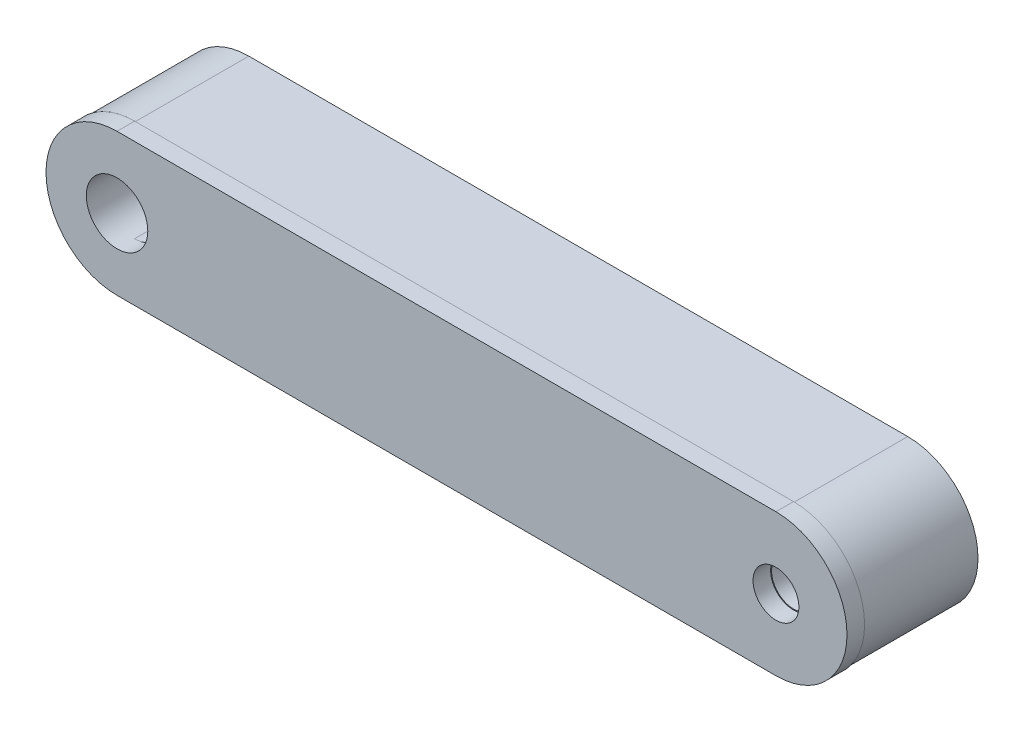
from build123d import *

# Parameters (mm, degrees)
SKETCH1_R           = 2.5
BOSS_EXTRUDE1_DEPTH = 13
SKETCH2_R           = 2.609917525
SKETCH2_R_2         = 3.5
BOSS_EXTRUDE2_DEPTH = 2


with BuildPart() as part:
    # Sketch1 → Boss-Extrude1 (new body)
    with BuildSketch(Plane.XY):
        with BuildLine():
            Line((-89.768287337, 45.333507938), (-14.768287337, 45.333507938))
            ThreePointArc((-14.768287337, 45.333507938), (-6.770739373, 37.335959975), (-14.768287337, 29.338412011))
            Line((-14.768287337, 29.338412011), (-89.768287337, 29.338412011))
            ThreePointArc((-89.768287337, 29.338412011), (-97.765835301, 37.335959975), (-89.768287337, 45.333507938))
        make_face()
        with Locations((-14.768287337, 37.335959975)):
            Circle(SKETCH1_R, mode=Mode.SUBTRACT)
        with BuildLine():
            Line((-89.768287337, 40.835959975), (-77.768287337, 40.835959975))
            ThreePointArc((-77.768287337, 40.835959975), (-74.268287337, 37.335959975), (-77.768287337, 33.835959975))
            Line((-77.768287337, 33.835959975), (-89.768287337, 33.835959975))
            ThreePointArc((-89.768287337, 33.835959975), (-93.268287337, 37.335959975), (-89.768287337, 40.835959975))
        make_face(mode=Mode.SUBTRACT)
    extrude(amount=BOSS_EXTRUDE1_DEPTH)

    # Sketch2 → Boss-Extrude2 (add)
    with BuildSketch(Plane.XY.offset(13)):
        with BuildLine():
            Line((-89.768287337, 45.422284511), (-14.768287337, 45.422284511))
            ThreePointArc((-14.768287337, 45.422284511), (-6.681962801, 37.335959975), (-14.768287337, 29.249635439))
            Line((-14.768287337, 29.249635439), (-89.768287337, 29.249635439))
            ThreePointArc((-89.768287337, 29.249635439), (-97.854611873, 37.335959975), (-89.768287337, 45.422284511))
        make_face()
        with Locations((-14.768287337, 37.335959975)):
            Circle(SKETCH2_R, mode=Mode.SUBTRACT)
        with Locations((-89.768287337, 37.335959975)):
            Circle(SKETCH2_R_2, mode=Mode.SUBTRACT)
    extrude(amount=BOSS_EXTRUDE2_DEPTH)


solid = part.part
